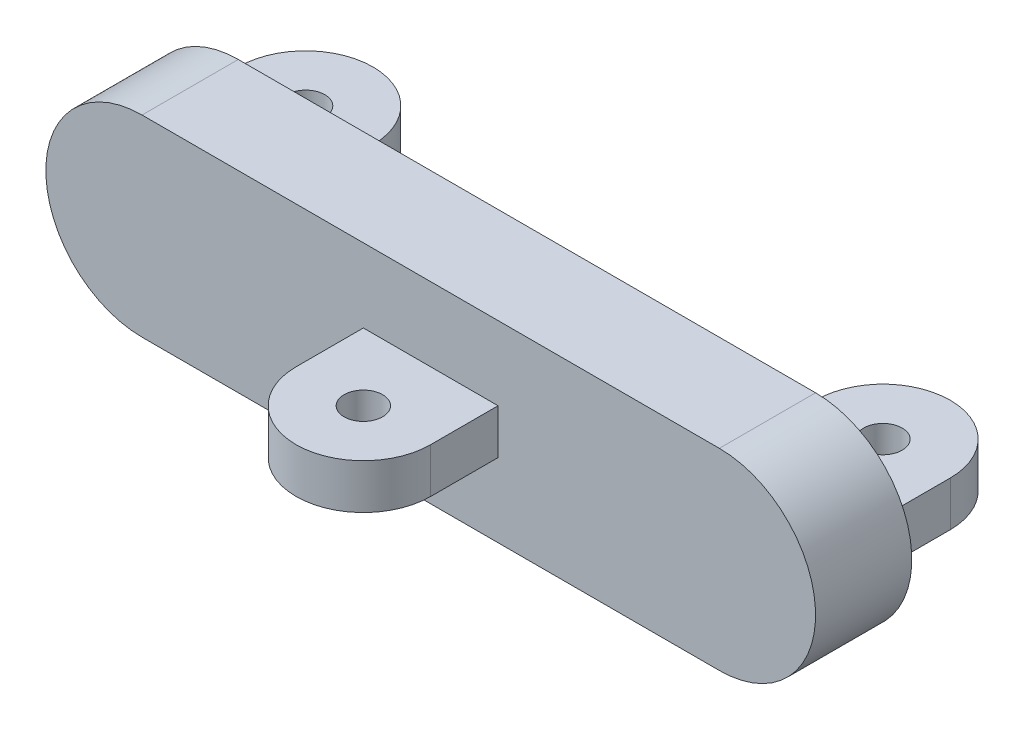
from build123d import *

# Parameters (mm, degrees)
BOSS_EXTRUDE1_DEPTH = 5
SKETCH3_W           = 7
SKETCH3_H           = 2.333333334
BOSS_EXTRUDE2_DEPTH = 3.5
SKETCH6_W           = 3.5
SKETCH6_H           = 2.333333334
REVOLVE1_ANGLE      = 180
CUT_EXTRUDE1_REACH  = 24.069
SKETCH7_R           = 1
SKETCH8_W           = 7
SKETCH8_H           = 2.33
BOSS_EXTRUDE3_DEPTH = 3.5
SKETCH9_W           = 3.5
SKETCH9_H           = 2.33
REVOLVE2_ANGLE      = 180
SKETCH9_3_W         = 3.5
SKETCH9_3_H         = 2.33
REVOLVE3_ANGLE      = 180
CUT_EXTRUDE2_REACH  = 26.125
SKETCH11_R          = 1


with BuildPart() as part:
    # Sketch2 → Boss-Extrude1 (new body)
    with BuildSketch(Plane.XY):
        with BuildLine():
            Line((-15, -5), (15, -5))
            ThreePointArc((15, -5), (20, 0), (15, 5))
            Line((15, 5), (-15, 5))
            ThreePointArc((-15, 5), (-20, 0), (-15, -5))
        make_face()
    extrude(amount=-BOSS_EXTRUDE1_DEPTH)

    # Sketch3 → Boss-Extrude2 (add)
    with BuildSketch(Plane.XY):
        Rectangle(SKETCH3_W, SKETCH3_H)
    extrude(amount=BOSS_EXTRUDE2_DEPTH)

    # Sketch6 → Revolve1 (revolve)
    with BuildSketch(Plane.XY.offset(3.5)):
        with Locations((-1.75, 0)):
            Rectangle(SKETCH6_W, SKETCH6_H)
    revolve(axis=Axis((0, 1.166666667, 3.5), (0, 1, 0)), revolution_arc=REVOLVE1_ANGLE)

    # Sketch7 → Cut-Extrude1 (cut, up to next)
    with BuildSketch(Plane(origin=(0, 1.166666667, 0), x_dir=(1, 0, 0), z_dir=(0, 1, 0)), mode=Mode.PRIVATE) as cut_extrude1_sk1:
        with Locations((0, -3.5)):
            Circle(SKETCH7_R)
    cut_extrude1_tool1 = extrude(cut_extrude1_sk1.sketch, amount=-CUT_EXTRUDE1_REACH, mode=Mode.PRIVATE) & part.part
    add(cut_extrude1_tool1.solids().sort_by_distance((0, 1.166667, 3.5))[0], mode=Mode.SUBTRACT)

    # Sketch8 → Boss-Extrude3 (add)
    with BuildSketch(Plane(origin=(0, 0, -5), x_dir=(-1, 0, 0), z_dir=(0, 0, -1))):
        with Locations((-15, 0)):
            Rectangle(SKETCH8_W, SKETCH8_H)
        with Locations((15, 0)):
            Rectangle(SKETCH8_W, SKETCH8_H)
    extrude(amount=BOSS_EXTRUDE3_DEPTH)

    # Sketch9 → Revolve2 (revolve)
    with BuildSketch(Plane(origin=(0, 0, -8.5), x_dir=(-1, 0, 0), z_dir=(0, 0, -1))):
        with Locations((-16.75, 0)):
            Rectangle(SKETCH9_W, SKETCH9_H)
    revolve(axis=Axis((15, 1.165, -8.5), (0, 1, 0)), revolution_arc=REVOLVE2_ANGLE)

    # Sketch9_3 → Revolve3 (revolve)
    with BuildSketch(Plane(origin=(0, 0, -8.5), x_dir=(-1, 0, 0), z_dir=(0, 0, -1))):
        with Locations((13.25, 0)):
            Rectangle(SKETCH9_3_W, SKETCH9_3_H)
    revolve(axis=Axis((-15, 1.165, -8.5), (0, 1, 0)), revolution_arc=REVOLVE3_ANGLE)

    # Sketch11 → Cut-Extrude2 (cut, up to next)
    with BuildSketch(Plane(origin=(0, 1.165, 0), x_dir=(1, 0, 0), z_dir=(0, 1, 0)), mode=Mode.PRIVATE) as cut_extrude2_sk1:
        with Locations((-15, 8.5)):
            Circle(SKETCH11_R)
    cut_extrude2_tool1 = extrude(cut_extrude2_sk1.sketch, amount=-CUT_EXTRUDE2_REACH, mode=Mode.PRIVATE) & part.part
    # Sketch11 → Cut-Extrude2 (cut, up to next)
    with BuildSketch(Plane(origin=(0, 1.165, 0), x_dir=(1, 0, 0), z_dir=(0, 1, 0)), mode=Mode.PRIVATE) as cut_extrude2_sk2:
        with Locations((15, 8.5)):
            Circle(SKETCH11_R)
    cut_extrude2_tool2 = extrude(cut_extrude2_sk2.sketch, amount=-CUT_EXTRUDE2_REACH, mode=Mode.PRIVATE) & part.part
    add(cut_extrude2_tool1.solids().sort_by_distance((-15, 1.165, -8.5))[0], mode=Mode.SUBTRACT)
    add(cut_extrude2_tool2.solids().sort_by_distance((15, 1.165, -8.5))[0], mode=Mode.SUBTRACT)


solid = part.part
